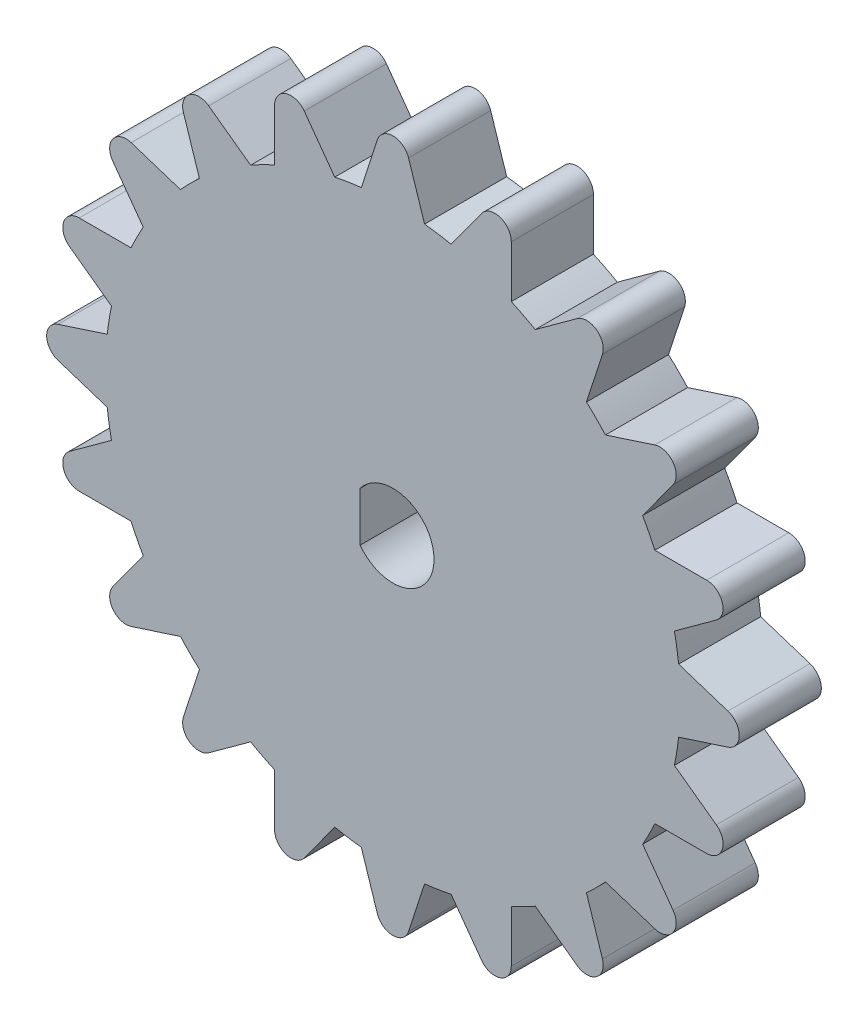
from build123d import *

# Parameters (mm, degrees)
DODANIE_WYCI_GNI_CIE1_DEPTH = 5


with BuildPart() as part:
    # Szkic1 → Dodanie-wyciągnięcie1 (new body)
    with BuildSketch(Plane.XY):
        with BuildLine():
            Line((-0.951045555, 20.39370068), (-1.925922284, 17.39370068))
            ThreePointArc((-1.925922284, 17.39370068), (-2.737603138, 17.28454596), (-3.543288168, 17.13753509))
            Line((-3.543288168, 17.13753509), (-5.397502016, 19.689451162))
            ThreePointArc((-5.397502016, 19.689451162), (-6.515515156, 20.052693732), (-7.206498161, 19.101672684))
            Line((-7.206498161, 19.101672684), (-7.206610043, 15.947249659))
            ThreePointArc((-7.206610043, 15.947249659), (-7.944833745, 15.592614173), (-8.665656885, 15.203828161))
            Line((-8.665656885, 15.203828161), (-11.217704483, 17.05786098))
            ThreePointArc((-11.217704483, 17.05786098), (-12.393246293, 17.057840133), (-12.756528516, 15.939839877))
            Line((-12.756528516, 15.939839877), (-11.7818646, 12.93977073))
            ThreePointArc((-11.7818646, 12.93977073), (-12.374368671, 12.374368671), (-12.93977073, 11.7818646))
            Line((-12.93977073, 11.7818646), (-15.939839877, 12.756528516))
            ThreePointArc((-15.939839877, 12.756528516), (-17.057840133, 12.393246293), (-17.05786098, 11.217704483))
            Line((-17.05786098, 11.217704483), (-15.203828161, 8.665656885))
            ThreePointArc((-15.203828161, 8.665656885), (-15.592614173, 7.944833745), (-15.947249659, 7.206610043))
            Line((-15.947249659, 7.206610043), (-19.101672684, 7.206498161))
            ThreePointArc((-19.101672684, 7.206498161), (-20.052693732, 6.515515156), (-19.689451162, 5.397502016))
            Line((-19.689451162, 5.397502016), (-17.13753509, 3.543288168))
            ThreePointArc((-17.13753509, 3.543288168), (-17.28454596, 2.737603138), (-17.39370068, 1.925922284))
            Line((-17.39370068, 1.925922284), (-20.39370068, 0.951045555))
            ThreePointArc((-20.39370068, 0.951045555), (-21.084649954, 0), (-20.39370068, -0.951045555))
            Line((-20.39370068, -0.951045555), (-17.39370068, -1.925922284))
            ThreePointArc((-17.39370068, -1.925922284), (-17.28454596, -2.737603138), (-17.13753509, -3.543288168))
            Line((-17.13753509, -3.543288168), (-19.689451162, -5.397502016))
            ThreePointArc((-19.689451162, -5.397502016), (-20.052693732, -6.515515156), (-19.101672684, -7.206498161))
            Line((-19.101672684, -7.206498161), (-15.947249659, -7.206610043))
            ThreePointArc((-15.947249659, -7.206610043), (-15.592614173, -7.944833745), (-15.203828161, -8.665656885))
            Line((-15.203828161, -8.665656885), (-17.05786098, -11.217704483))
            ThreePointArc((-17.05786098, -11.217704483), (-17.057840133, -12.393246293), (-15.939839877, -12.756528516))
            Line((-15.939839877, -12.756528516), (-12.93977073, -11.7818646))
            ThreePointArc((-12.93977073, -11.7818646), (-12.374368671, -12.374368671), (-11.7818646, -12.93977073))
            Line((-11.7818646, -12.93977073), (-12.756528516, -15.939839877))
            ThreePointArc((-12.756528516, -15.939839877), (-12.393246293, -17.057840133), (-11.217704483, -17.05786098))
            Line((-11.217704483, -17.05786098), (-8.665656885, -15.203828161))
            ThreePointArc((-8.665656885, -15.203828161), (-7.944833745, -15.592614173), (-7.206610043, -15.947249659))
            Line((-7.206610043, -15.947249659), (-7.206498161, -19.101672684))
            ThreePointArc((-7.206498161, -19.101672684), (-6.515515156, -20.052693732), (-5.397502016, -19.689451162))
            Line((-5.397502016, -19.689451162), (-3.543288168, -17.13753509))
            ThreePointArc((-3.543288168, -17.13753509), (-2.737603138, -17.28454596), (-1.925922284, -17.39370068))
            Line((-1.925922284, -17.39370068), (-0.951045555, -20.39370068))
            ThreePointArc((-0.951045555, -20.39370068), (0, -21.084649954), (0.951045555, -20.39370068))
            Line((0.951045555, -20.39370068), (1.925922284, -17.39370068))
            ThreePointArc((1.925922284, -17.39370068), (2.737603138, -17.28454596), (3.543288168, -17.13753509))
            Line((3.543288168, -17.13753509), (5.397502016, -19.689451162))
            ThreePointArc((5.397502016, -19.689451162), (6.515515156, -20.052693732), (7.206498161, -19.101672684))
            Line((7.206498161, -19.101672684), (7.206610043, -15.947249659))
            ThreePointArc((7.206610043, -15.947249659), (7.944833745, -15.592614173), (8.665656885, -15.203828161))
            Line((8.665656885, -15.203828161), (11.217704483, -17.05786098))
            ThreePointArc((11.217704483, -17.05786098), (12.393246293, -17.057840133), (12.756528516, -15.939839877))
            Line((12.756528516, -15.939839877), (11.7818646, -12.93977073))
            ThreePointArc((11.7818646, -12.93977073), (12.374368671, -12.374368671), (12.93977073, -11.7818646))
            Line((12.93977073, -11.7818646), (15.939839877, -12.756528516))
            ThreePointArc((15.939839877, -12.756528516), (17.057840133, -12.393246293), (17.05786098, -11.217704483))
            Line((17.05786098, -11.217704483), (15.203828161, -8.665656885))
            ThreePointArc((15.203828161, -8.665656885), (15.592614173, -7.944833745), (15.947249659, -7.206610043))
            Line((15.947249659, -7.206610043), (19.101672684, -7.206498161))
            ThreePointArc((19.101672684, -7.206498161), (20.052693732, -6.515515156), (19.689451162, -5.397502016))
            Line((19.689451162, -5.397502016), (17.13753509, -3.543288168))
            ThreePointArc((17.13753509, -3.543288168), (17.28454596, -2.737603138), (17.39370068, -1.925922284))
            Line((17.39370068, -1.925922284), (20.39370068, -0.951045555))
            ThreePointArc((20.39370068, -0.951045555), (21.084649954, 0), (20.39370068, 0.951045555))
            Line((20.39370068, 0.951045555), (17.39370068, 1.925922284))
            ThreePointArc((17.39370068, 1.925922284), (17.28454596, 2.737603138), (17.13753509, 3.543288168))
            Line((17.13753509, 3.543288168), (19.689451162, 5.397502016))
            ThreePointArc((19.689451162, 5.397502016), (20.052693732, 6.515515156), (19.101672684, 7.206498161))
            Line((19.101672684, 7.206498161), (15.947249659, 7.206610043))
            ThreePointArc((15.947249659, 7.206610043), (15.592614173, 7.944833745), (15.203828161, 8.665656885))
            Line((15.203828161, 8.665656885), (17.05786098, 11.217704483))
            ThreePointArc((17.05786098, 11.217704483), (17.057840133, 12.393246293), (15.939839877, 12.756528516))
            Line((15.939839877, 12.756528516), (12.93977073, 11.7818646))
            ThreePointArc((12.93977073, 11.7818646), (12.374368671, 12.374368671), (11.7818646, 12.93977073))
            Line((11.7818646, 12.93977073), (12.756528516, 15.939839877))
            ThreePointArc((12.756528516, 15.939839877), (12.393246293, 17.057840133), (11.217704483, 17.05786098))
            Line((11.217704483, 17.05786098), (8.665656885, 15.203828161))
            ThreePointArc((8.665656885, 15.203828161), (7.944833745, 15.592614173), (7.206610043, 15.947249659))
            Line((7.206610043, 15.947249659), (7.206498161, 19.101672684))
            ThreePointArc((7.206498161, 19.101672684), (6.515515156, 20.052693732), (5.397502016, 19.689451162))
            Line((5.397502016, 19.689451162), (3.543288168, 17.13753509))
            ThreePointArc((3.543288168, 17.13753509), (2.737603138, 17.28454596), (1.925922284, 17.39370068))
            Line((1.925922284, 17.39370068), (0.951045555, 20.39370068))
            ThreePointArc((0.951045555, 20.39370068), (0, 21.084649954), (-0.951045555, 20.39370068))
        make_face()
        with BuildLine():
            Line((-2, 1.5), (-2, -1.5))
            ThreePointArc((-2, -1.5), (2.5, 0), (-2, 1.5))
        make_face(mode=Mode.SUBTRACT)
    extrude(amount=DODANIE_WYCI_GNI_CIE1_DEPTH)


solid = part.part
